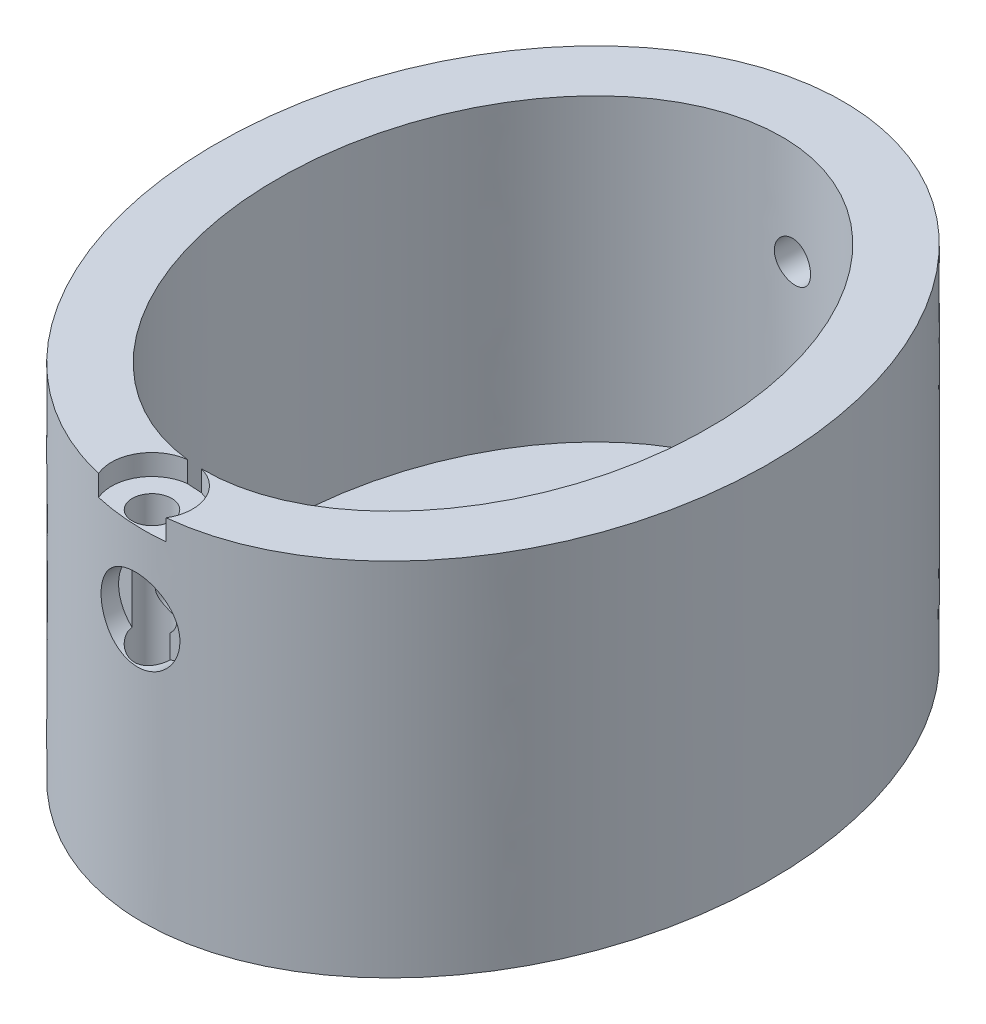
from build123d import *

# Parameters (mm, degrees)
SKETCH1_RX                                          = 29.072246502
SKETCH1_RY                                          = 22.9873577
BOSS_EXTRUDE1_DEPTH                                 = 29.972
SHELL1_T                                            = -5.08
CBORE_FOR_4_BINDING_HEAD_MACHINE_SCREW1_D           = 3.2639
CBORE_FOR_4_BINDING_HEAD_MACHINE_SCREW1_CBORE_D     = 6.74624
CBORE_FOR_4_BINDING_HEAD_MACHINE_SCREW1_CBORE_DEPTH = 1.7272
CBORE_FOR_4_BINDING_HEAD_MACHINE_SCREW2_D           = 3.2639
CBORE_FOR_4_BINDING_HEAD_MACHINE_SCREW2_CBORE_D     = 6.74624
CBORE_FOR_4_BINDING_HEAD_MACHINE_SCREW2_CBORE_DEPTH = 1.7272


with BuildPart() as part:
    # Sketch1 → Boss-Extrude1 (new body)
    with BuildSketch(Plane(origin=(0, 0, 0), x_dir=(1, 0, 0), z_dir=(0, 1, 0))):
        with Locations(Location((0, 0), (0, 0, -90))):
            Ellipse(SKETCH1_RX, SKETCH1_RY)
    extrude(amount=BOSS_EXTRUDE1_DEPTH)

    # Shell1
    shell1_openings = [part.faces().sort_by_distance(p)[0] for p in [
        (0, 29.972, 0),
    ]]
    offset(amount=SHELL1_T, openings=shell1_openings, kind=Kind.INTERSECTION)

    # CBORE for #4 Binding Head Machine Screw1 (through all)
    with Locations(Plane(origin=(0, 29.972, 0), x_dir=(1, 0, 0), z_dir=(0, 1, 0))):
        with Locations((-1.060202343, -27.256035238)):
            CounterBoreHole(CBORE_FOR_4_BINDING_HEAD_MACHINE_SCREW1_D / 2, CBORE_FOR_4_BINDING_HEAD_MACHINE_SCREW1_CBORE_D / 2, CBORE_FOR_4_BINDING_HEAD_MACHINE_SCREW1_CBORE_DEPTH)

    # CBORE for #4 Binding Head Machine Screw2 (through all)
    with Locations(Plane(origin=(-0.530101172, 21.513594933, 29.064515323), x_dir=(0.999574752, 0, 0.029160169), z_dir=(-0.029160169, 0, 0.999574752))):
        with Locations((0, 0)):
            CounterBoreHole(CBORE_FOR_4_BINDING_HEAD_MACHINE_SCREW2_D / 2, CBORE_FOR_4_BINDING_HEAD_MACHINE_SCREW2_CBORE_D / 2, CBORE_FOR_4_BINDING_HEAD_MACHINE_SCREW2_CBORE_DEPTH)


solid = part.part
